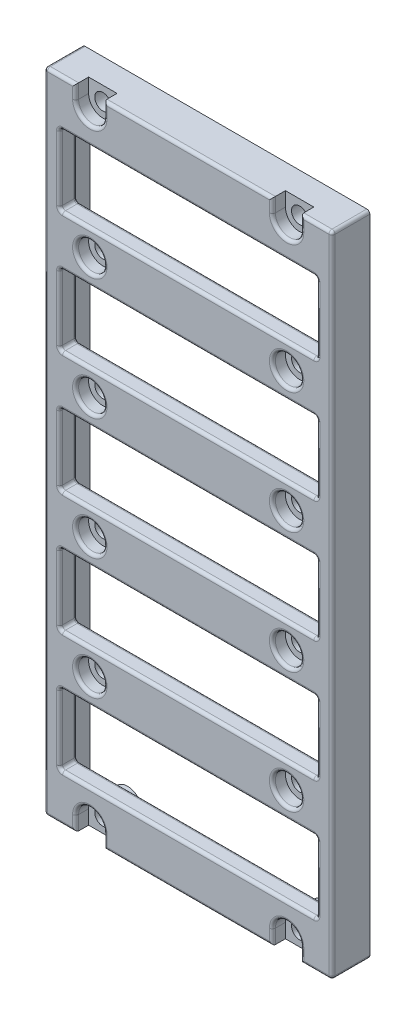
from build123d import *

# Parameters (mm, degrees)
BOSS_EXTRUDE1_DEPTH                            = 6.35
CBORE_FOR_2_SOCKET_HEAD_CAP_SCREW1_D           = 2.7051
CBORE_FOR_2_SOCKET_HEAD_CAP_SCREW1_CBORE_D     = 4.7625
CBORE_FOR_2_SOCKET_HEAD_CAP_SCREW1_CBORE_DEPTH = 2.1844
SKETCH4_W                                      = 4.7625
SKETCH4_H                                      = 2.3876
CUT_EXTRUDE1_DEPTH                             = 2.1844
SKETCH5_W                                      = 43.18
SKETCH5_H                                      = 11.90625
CUT_EXTRUDE2_DEPTH                             = 7.35
SKETCH6_R                                      = 2.38125
SKETCH6_W                                      = 43.18
SKETCH6_H                                      = 11.90625
CUT_EXTRUDE3_DEPTH                             = 3.4036
FILLET1_R                                      = 0.508
SKETCH7_W                                      = 39.926180477
SKETCH7_H                                      = 73.723340944
CUT_EXTRUDE4_DEPTH                             = 2.54


with BuildPart() as part:
    # Sketch1 → Boss-Extrude1 (new body)
    with BuildSketch(Plane.XY):
        Polygon((-15.24, -177.7842297), (-15.24, -72.1202297), (-15.24, -70.5962297), (-63.5, -70.5962297), (-63.5, -72.1202297), (-63.5, -177.7842297), (-63.5, -179.3082297), (-15.24, -179.3082297), align=None)
    extrude(amount=BOSS_EXTRUDE1_DEPTH)

    # CBORE for #2 Socket Head Cap Screw1 (through all)
    with Locations(Plane.XY.offset(6.35)):
        with Locations((-55.88, -72.9838297), (-22.86, -72.9838297), (-22.86, -94.4722297), (-22.86, -114.7922297), (-22.86, -135.1122297), (-22.86, -155.4322297), (-22.86, -176.9206297), (-55.88, -176.9206297), (-55.88, -155.4322297), (-55.88, -135.1122297), (-55.88, -114.7922297), (-55.88, -94.4722297)):
            CounterBoreHole(CBORE_FOR_2_SOCKET_HEAD_CAP_SCREW1_D / 2, CBORE_FOR_2_SOCKET_HEAD_CAP_SCREW1_CBORE_D / 2, CBORE_FOR_2_SOCKET_HEAD_CAP_SCREW1_CBORE_DEPTH)

    # Sketch4 → Cut-Extrude1 (cut)
    with BuildSketch(Plane.XY.offset(6.35)):
        with Locations((-22.86, -178.1144297)):
            Rectangle(SKETCH4_W, SKETCH4_H)
        with Locations((-55.88, -178.1144297)):
            Rectangle(SKETCH4_W, SKETCH4_H)
        with Locations((-22.86, -71.7900297)):
            Rectangle(SKETCH4_W, SKETCH4_H)
        with Locations((-55.88, -71.7900297)):
            Rectangle(SKETCH4_W, SKETCH4_H)
    extrude(amount=-CUT_EXTRUDE1_DEPTH, mode=Mode.SUBTRACT)

    # Sketch5 → Cut-Extrude2 (cut, through all)
    with BuildSketch(Plane.XY.offset(6.35)):
        with Locations((-39.37, -165.5922297)):
            Rectangle(SKETCH5_W, SKETCH5_H)
        with Locations((-39.37, -145.2722297)):
            Rectangle(SKETCH5_W, SKETCH5_H)
        with Locations((-39.37, -124.9522297)):
            Rectangle(SKETCH5_W, SKETCH5_H)
        with Locations((-39.37, -104.6322297)):
            Rectangle(SKETCH5_W, SKETCH5_H)
        with Locations((-39.37, -84.3122297)):
            Rectangle(SKETCH5_W, SKETCH5_H)
    extrude(amount=-CUT_EXTRUDE2_DEPTH, mode=Mode.SUBTRACT)

    # Sketch6 → Cut-Extrude3 (cut)
    with BuildSketch(Plane(origin=(0, 0, 0), x_dir=(-1, 0, 0), z_dir=(0, 0, -1))):
        with BuildLine():
            Line((20.47875, -72.9838297), (20.47875, -71.8662297))
            Line((20.47875, -71.8662297), (16.51, -71.8662297))
            Line((16.51, -71.8662297), (16.51, -178.0382297))
            Line((16.51, -178.0382297), (20.47875, -178.0382297))
            Line((20.47875, -178.0382297), (20.47875, -176.9206297))
            ThreePointArc((20.47875, -176.9206297), (22.86, -174.5393797), (25.24125, -176.9206297))
            Line((25.24125, -176.9206297), (25.24125, -178.0382297))
            Line((25.24125, -178.0382297), (53.49875, -178.0382297))
            Line((53.49875, -178.0382297), (53.49875, -176.9206297))
            ThreePointArc((53.49875, -176.9206297), (55.88, -174.5393797), (58.26125, -176.9206297))
            Line((58.26125, -176.9206297), (58.26125, -178.0382297))
            Line((58.26125, -178.0382297), (62.23, -178.0382297))
            Line((62.23, -178.0382297), (62.23, -71.8662297))
            Line((62.23, -71.8662297), (58.26125, -71.8662297))
            Line((58.26125, -71.8662297), (58.26125, -72.9838297))
            ThreePointArc((58.26125, -72.9838297), (55.88, -75.3650797), (53.49875, -72.9838297))
            Line((53.49875, -72.9838297), (53.49875, -71.8662297))
            Line((53.49875, -71.8662297), (25.24125, -71.8662297))
            Line((25.24125, -71.8662297), (25.24125, -72.9838297))
            ThreePointArc((25.24125, -72.9838297), (22.86, -75.3650797), (20.47875, -72.9838297))
        make_face()
        with Locations((55.88, -155.4322297)):
            Circle(SKETCH6_R, mode=Mode.SUBTRACT)
        with Locations((22.86, -155.4322297)):
            Circle(SKETCH6_R, mode=Mode.SUBTRACT)
        with Locations((22.86, -135.1122297)):
            Circle(SKETCH6_R, mode=Mode.SUBTRACT)
        with Locations((55.88, -135.1122297)):
            Circle(SKETCH6_R, mode=Mode.SUBTRACT)
        with Locations((55.88, -114.7922297)):
            Circle(SKETCH6_R, mode=Mode.SUBTRACT)
        with Locations((22.86, -114.7922297)):
            Circle(SKETCH6_R, mode=Mode.SUBTRACT)
        with Locations((22.86, -94.4722297)):
            Circle(SKETCH6_R, mode=Mode.SUBTRACT)
        with Locations((55.88, -94.4722297)):
            Circle(SKETCH6_R, mode=Mode.SUBTRACT)
        with Locations((39.37, -104.6322297)):
            Rectangle(SKETCH6_W, SKETCH6_H, mode=Mode.SUBTRACT)
        with Locations((39.37, -84.3122297)):
            Rectangle(SKETCH6_W, SKETCH6_H, mode=Mode.SUBTRACT)
        with Locations((39.37, -124.9522297)):
            Rectangle(SKETCH6_W, SKETCH6_H, mode=Mode.SUBTRACT)
        with Locations((39.37, -145.2722297)):
            Rectangle(SKETCH6_W, SKETCH6_H, mode=Mode.SUBTRACT)
        with Locations((39.37, -165.5922297)):
            Rectangle(SKETCH6_W, SKETCH6_H, mode=Mode.SUBTRACT)
    extrude(amount=-CUT_EXTRUDE3_DEPTH, mode=Mode.SUBTRACT)

    # Fillet1
    fillet1_edges = [part.edges().sort_by_distance(p)[0] for p in [
        (-25.24125, -114.7922297, 6.35),
        (-25.24125, -94.4722297, 6.35),
        (-17.859375, -70.5962297, 6.35),
        (-17.859375, -179.3082297, 6.35),
        (-15.24, -179.3082297, 3.175),
        (-25.24125, -178.1144297, 6.35),
        (-20.47875, -178.1144297, 6.35),
        (-63.5, -179.3082297, 3.175),
        (-63.5, -70.5962297, 3.175),
        (-15.24, -70.5962297, 3.175),
        (-39.37, -179.3082297, 6.35),
        (-53.49875, -178.1144297, 6.35),
        (-58.26125, -178.1144297, 6.35),
        (-63.5, -124.9522297, 6.35),
        (-22.86, -75.3650797, 6.35),
        (-39.37, -70.5962297, 6.35),
        (-25.24125, -71.7900297, 6.35),
        (-20.47875, -71.7900297, 6.35),
        (-55.88, -75.3650797, 6.35),
        (-60.880625, -70.5962297, 6.35),
        (-58.26125, -71.7900297, 6.35),
        (-53.49875, -71.7900297, 6.35),
        (-17.78, -165.5922297, 6.35),
        (-39.37, -159.6391047, 6.35),
        (-60.96, -165.5922297, 6.35),
        (-39.37, -171.5453547, 6.35),
        (-39.37, -151.2253547, 6.35),
        (-17.78, -145.2722297, 6.35),
        (-39.37, -139.3191047, 6.35),
        (-60.96, -145.2722297, 6.35),
        (-39.37, -130.9053547, 6.35),
        (-17.78, -124.9522297, 6.35),
        (-39.37, -118.9991047, 6.35),
        (-60.96, -124.9522297, 6.35),
        (-39.37, -110.5853547, 6.35),
        (-17.78, -104.6322297, 6.35),
        (-39.37, -98.6791047, 6.35),
        (-60.96, -104.6322297, 6.35),
        (-60.880625, -179.3082297, 6.35),
        (-39.37, -90.2653547, 6.35),
        (-17.78, -84.3122297, 6.35),
        (-39.37, -78.3591047, 6.35),
        (-60.96, -84.3122297, 6.35),
        (-17.78, -78.3591047, 4.8768),
        (-17.78, -90.2653547, 4.8768),
        (-60.96, -78.3591047, 4.8768),
        (-60.96, -90.2653547, 4.8768),
        (-17.78, -98.6791047, 4.8768),
        (-17.78, -110.5853547, 4.8768),
        (-60.96, -98.6791047, 4.8768),
        (-60.96, -110.5853547, 4.8768),
        (-17.78, -118.9991047, 4.8768),
        (-17.78, -130.9053547, 4.8768),
        (-60.96, -118.9991047, 4.8768),
        (-60.96, -130.9053547, 4.8768),
        (-17.78, -139.3191047, 4.8768),
        (-17.78, -151.2253547, 4.8768),
        (-60.96, -139.3191047, 4.8768),
        (-60.96, -151.2253547, 4.8768),
        (-60.96, -159.6391047, 4.8768),
        (-17.78, -159.6391047, 4.8768),
        (-60.96, -171.5453547, 4.8768),
        (-17.78, -171.5453547, 4.8768),
        (-20.47875, -71.8662297, 1.7018),
        (-16.51, -71.8662297, 1.7018),
        (-16.51, -178.0382297, 1.7018),
        (-20.47875, -178.0382297, 1.7018),
        (-25.24125, -178.0382297, 1.7018),
        (-53.49875, -178.0382297, 1.7018),
        (-58.26125, -178.0382297, 1.7018),
        (-62.23, -178.0382297, 1.7018),
        (-62.23, -71.8662297, 1.7018),
        (-58.26125, -71.8662297, 1.7018),
        (-53.49875, -71.8662297, 1.7018),
        (-25.24125, -71.8662297, 1.7018),
        (-53.49875, -155.4322297, 3.4036),
        (-20.47875, -155.4322297, 3.4036),
        (-20.47875, -135.1122297, 3.4036),
        (-53.49875, -135.1122297, 3.4036),
        (-53.49875, -114.7922297, 3.4036),
        (-20.47875, -114.7922297, 3.4036),
        (-20.47875, -94.4722297, 3.4036),
        (-53.49875, -94.4722297, 3.4036),
        (-39.37, -98.6791047, 3.4036),
        (-17.78, -104.6322297, 3.4036),
        (-39.37, -110.5853547, 3.4036),
        (-60.96, -104.6322297, 3.4036),
        (-39.37, -78.3591047, 3.4036),
        (-17.78, -84.3122297, 3.4036),
        (-39.37, -90.2653547, 3.4036),
        (-60.96, -84.3122297, 3.4036),
        (-39.37, -118.9991047, 3.4036),
        (-17.78, -124.9522297, 3.4036),
        (-39.37, -130.9053547, 3.4036),
        (-60.96, -124.9522297, 3.4036),
        (-39.37, -139.3191047, 3.4036),
        (-17.78, -145.2722297, 3.4036),
        (-39.37, -151.2253547, 3.4036),
        (-60.96, -145.2722297, 3.4036),
        (-60.96, -165.5922297, 3.4036),
        (-39.37, -159.6391047, 3.4036),
        (-17.78, -165.5922297, 3.4036),
        (-39.37, -171.5453547, 3.4036),
        (-22.86, -75.3650797, 3.4036),
        (-25.24125, -72.4250297, 3.4036),
        (-39.37, -71.8662297, 3.4036),
        (-53.49875, -72.4250297, 3.4036),
        (-55.88, -75.3650797, 3.4036),
        (-58.26125, -72.4250297, 3.4036),
        (-60.245625, -71.8662297, 3.4036),
        (-62.23, -124.9522297, 3.4036),
        (-60.245625, -178.0382297, 3.4036),
        (-58.26125, -177.4794297, 3.4036),
        (-55.88, -174.5393797, 3.4036),
        (-53.49875, -177.4794297, 3.4036),
        (-39.37, -178.0382297, 3.4036),
        (-25.24125, -177.4794297, 3.4036),
        (-22.86, -174.5393797, 3.4036),
        (-20.47875, -177.4794297, 3.4036),
        (-18.494375, -178.0382297, 3.4036),
        (-16.51, -124.9522297, 3.4036),
        (-18.494375, -71.8662297, 3.4036),
        (-20.47875, -72.4250297, 3.4036),
        (-58.26125, -94.4722297, 6.35),
        (-15.24, -124.9522297, 6.35),
        (-58.26125, -114.7922297, 6.35),
        (-58.26125, -135.1122297, 6.35),
        (-58.26125, -155.4322297, 6.35),
        (-55.88, -174.5393797, 6.35),
        (-22.86, -174.5393797, 6.35),
        (-25.24125, -155.4322297, 6.35),
        (-25.24125, -135.1122297, 6.35),
    ]]
    fillet(fillet1_edges, radius=FILLET1_R)

    # Sketch7 → Cut-Extrude4 (cut)
    with BuildSketch(Plane(origin=(0, 0, 0), x_dir=(-1, 0, 0), z_dir=(0, 0, -1))):
        with Locations((39.544664201, -125.057111299)):
            Rectangle(SKETCH7_W, SKETCH7_H)
    extrude(amount=-CUT_EXTRUDE4_DEPTH, mode=Mode.SUBTRACT)


solid = part.part
